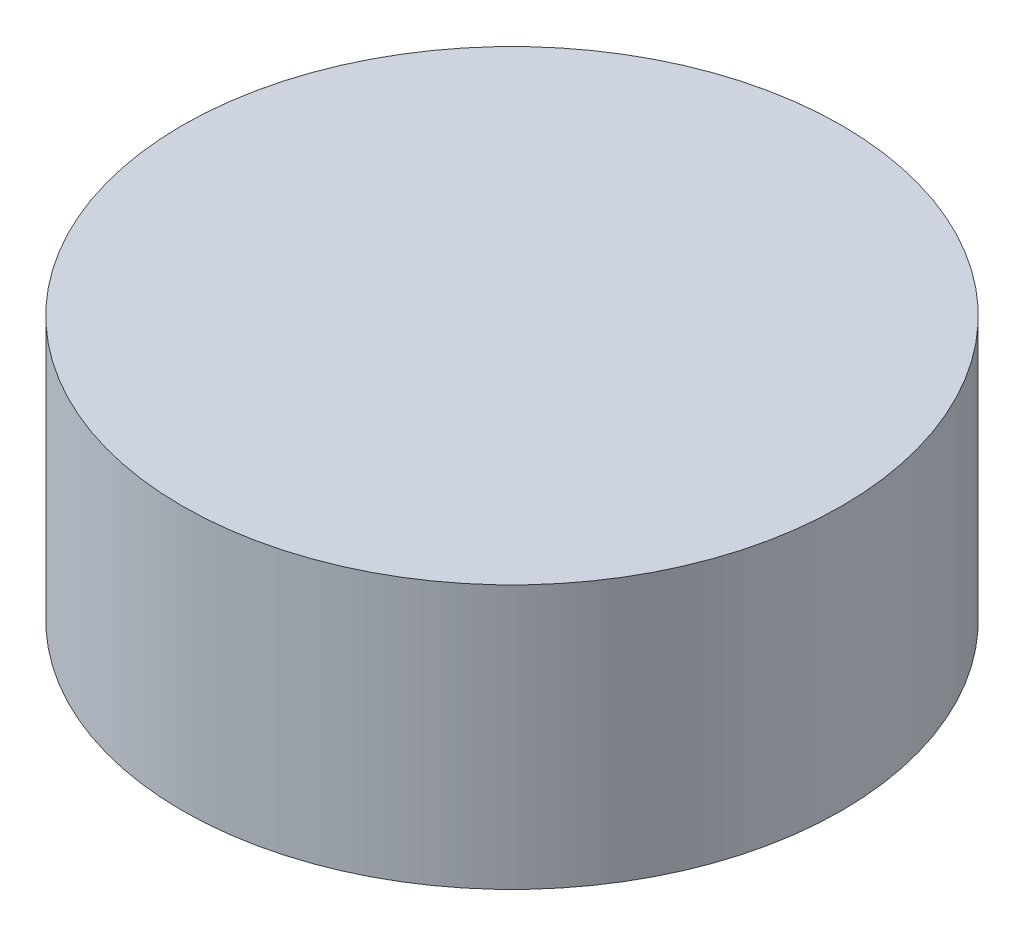
from build123d import *

# Parameters (mm, degrees)
SKETCH_1_R      = 5
EXTRUDE_1_DEPTH = 4


with BuildPart() as part:
    # 草圖1 → 填料-伸長1 (new body)
    with BuildSketch(Plane(origin=(0, 0, 0), x_dir=(1, 0, 0), z_dir=(0, 1, 0))):
        Circle(SKETCH_1_R)
    extrude(amount=EXTRUDE_1_DEPTH)


solid = part.part
